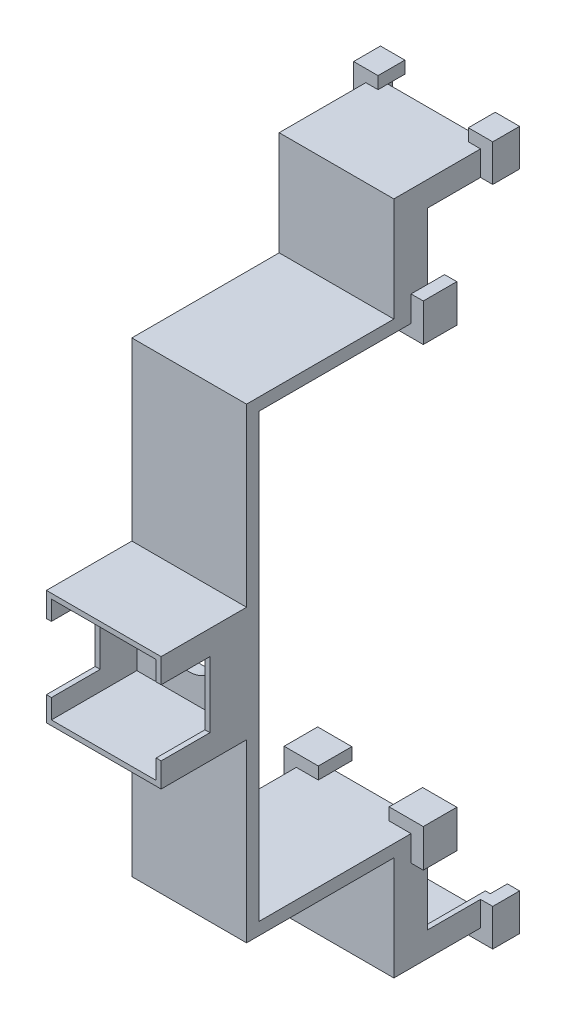
from build123d import *

# Parameters (mm, degrees)
SKETCH_1_W                = 46.3
SKETCH_1_H                = 47
EXTRUDE_1_DEPTH           = 50
SKETCH_2_W                = 46.3
SKETCH_2_H                = 42
CUT_EXTRUDE_1_DEPTH       = 32.3
SKETCH_3_W                = 42.3
SKETCH_3_H                = 40
CUT_EXTRUDE_2_DEPTH       = 10
SKETCH_4_W                = 42.3
SKETCH_4_H                = 37
CUT_EXTRUDE_3_DEPTH       = 8.7
SKETCH_5_W                = 2
SKETCH_5_H                = 22
SKETCH_5_W_2              = 26.3
SKETCH_5_H_2              = 2
CUT_EXTRUDE_4_DEPTH       = 5
SKETCH_7_W                = 10
SKETCH_7_H                = 5
EXTRUDE_2_DEPTH           = 2
SKETCH_8_W                = 10
SKETCH_8_H                = 5
EXTRUDE_3_DEPTH           = 2
SKETCH_9_W                = 22
SKETCH_9_H                = 21.15
CUT_EXTRUDE_5_DEPTH       = 6
SKETCH_11_R               = 2
EXTRUDE_4_DEPTH           = 4
SKETCH_12_R               = 2
CUT_EXTRUDE_6_DEPTH       = 4
SCALE_1_SCALE             = 1.015
SKETCH_13_W               = 33.453324454
SKETCH_13_H               = 20.869572599
CUT_EXTRUDE_7_DEPTH       = 57.79725
CUT_EXTRUDE_7_DEPTH_BACK  = 11.49725
EXTRUDE_START             = -47.22285
SKETCH_15_W               = 23.49725
SKETCH_15_H               = 95.575
EXTRUDE_5_DEPTH           = 5.075
SKETCH_16_R               = 11.165
CUT_EXTRUDE_9_DEPTH       = 1
CUT_EXTRUDE_9_DEPTH_BACK  = 48.222850293
SKETCH_17_W               = 23.49725
SKETCH_17_H               = 95.575
EXTRUDE_6_DEPTH           = 5.075
SKETCH_18_R               = 11.17
CUT_EXTRUDE_11_DEPTH      = 1
CUT_EXTRUDE_11_DEPTH_BACK = 48.222850293
EXTRUDE_START_2           = -42.14785
SKETCH_20_W               = 46.64725
SKETCH_20_H               = 4.191450632
EXTRUDE_7_DEPTH           = 10
EXTRUDE_START_3           = -66.517763
SKETCH_22_W               = 46.9945
SKETCH_22_H               = 69.05
EXTRUDE_8_DEPTH           = 5.075
SKETCH_24_W               = 13.7769009
SKETCH_24_H               = 42.63
EXTRUDE_10_DEPTH          = 46.9945
SKETCH_26_W               = 25.73
SKETCH_26_H               = 10.15
EXTRUDE_11_DEPTH          = 46.9945
CUT_EXTRUDE_START         = -142.00285
SKETCH_28_W               = 42.58725
SKETCH_28_H               = 7.64
CUT_EXTRUDE_13_DEPTH      = 25.73
EXTRUDE_12_DEPTH          = 7
EXTRUDE_12_2_DEPTH        = 7
EXTRUDE_14_DEPTH          = 7
EXTRUDE_14_2_DEPTH        = 7
EXTRUDE_15_DEPTH          = 4
EXTRUDE_16_DEPTH          = 6.73
SKETCH_31_W               = 24.506685575
SKETCH_31_H               = 120.544137908
CUT_EXTRUDE_14_DEPTH      = 11.15
CUT_EXTRUDE_14_DEPTH_BACK = 58.1445
SKETCH_34_W               = 46.9945
SKETCH_34_H               = 46.9945
EXTRUDE_17_DEPTH          = 35
SKETCH_33_W               = 42.9
SKETCH_33_H               = 42.9
CUT_EXTRUDE_15_DEPTH      = 35
SKETCH_35_W               = 20
SKETCH_35_H               = 26.9945
CUT_EXTRUDE_16_DEPTH      = 6
CUT_EXTRUDE_16_DEPTH_BACK = 52.9945


with BuildPart() as part:
    # 草圖1 → 填料-伸長1 (new body)
    with BuildSketch(Plane(origin=(0, 0, 0), x_dir=(1, 0, 0), z_dir=(0, 1, 0))):
        with Locations((23.15, 23.5)):
            Rectangle(SKETCH_1_W, SKETCH_1_H)
    extrude(amount=EXTRUDE_1_DEPTH)

    # 草圖2 → 除料-伸長1 (cut)
    with BuildSketch(Plane(origin=(0, 50, 0), x_dir=(1, 0, 0), z_dir=(0, 1, 0))):
        with Locations((23.15, 21)):
            Rectangle(SKETCH_2_W, SKETCH_2_H)
    extrude(amount=-CUT_EXTRUDE_1_DEPTH, mode=Mode.SUBTRACT)

    # 草圖3 → 除料-伸長2 (cut)
    with BuildSketch(Plane(origin=(0, 17.7, 0), x_dir=(1, 0, 0), z_dir=(0, 1, 0))):
        with Locations((23.15, 22)):
            Rectangle(SKETCH_3_W, SKETCH_3_H)
    extrude(amount=-CUT_EXTRUDE_2_DEPTH, mode=Mode.SUBTRACT)

    # 草圖4 → 除料-伸長3 (cut, through all)
    with BuildSketch(Plane(origin=(0, 7.7, 0), x_dir=(1, 0, 0), z_dir=(0, 1, 0))):
        with Locations((23.15, 23.5)):
            Rectangle(SKETCH_4_W, SKETCH_4_H)
    extrude(amount=-CUT_EXTRUDE_3_DEPTH, mode=Mode.SUBTRACT)

    # 草圖5 → 除料-伸長4 (cut)
    with BuildSketch(Plane(origin=(0, 17.7, 0), x_dir=(1, 0, 0), z_dir=(0, 1, 0))):
        with Locations((1, 21)):
            Rectangle(SKETCH_5_W, SKETCH_5_H)
        with Locations((45.3, 21)):
            Rectangle(SKETCH_5_W, SKETCH_5_H)
        with Locations((23.15, 1)):
            Rectangle(SKETCH_5_W_2, SKETCH_5_H_2)
    extrude(amount=-CUT_EXTRUDE_4_DEPTH, mode=Mode.SUBTRACT)

    # 草圖7 → 填料-伸長2 (add)
    with BuildSketch(Plane.ZY):
        with BuildLine():
            Line((-42, 32.7), (-42, 22.7))
            Line((-42, 22.7), (-32, 22.7))
            ThreePointArc((-32, 22.7), (-34.928932188, 29.771067812), (-42, 32.7))
        make_face()
        with Locations((-37, 20.2)):
            Rectangle(SKETCH_7_W, SKETCH_7_H)
    extrude(amount=-EXTRUDE_2_DEPTH)

    # 草圖8 → 填料-伸長3 (add)
    with BuildSketch(Plane(origin=(46.3, 0, 0), x_dir=(0, 0, -1), z_dir=(1, 0, 0))):
        with Locations((37, 20.2)):
            Rectangle(SKETCH_8_W, SKETCH_8_H)
        with BuildLine():
            Line((32, 22.7), (42, 22.7))
            Line((42, 22.7), (42, 32.7))
            ThreePointArc((42, 32.7), (34.928932188, 29.771067812), (32, 22.7))
        make_face()
    extrude(amount=-EXTRUDE_3_DEPTH)

    # 草圖9 → 除料-伸長5 (cut, through all)
    with BuildSketch(Plane.XY.offset(-42)):
        with BuildLine():
            ThreePointArc((34.15, 28.85), (23.15, 17.85), (12.15, 28.85))
            Line((12.15, 28.85), (34.15, 28.85))
        make_face()
        with Locations((23.15, 39.425)):
            Rectangle(SKETCH_9_W, SKETCH_9_H)
    extrude(amount=-CUT_EXTRUDE_5_DEPTH, mode=Mode.SUBTRACT)

    # 草圖11 → 填料-伸長4 (add)
    with BuildSketch(Plane.XZ):
        with BuildLine():
            Line((51.3, -5), (46.3, -5))
            Line((46.3, -5), (46.3, -15))
            Line((46.3, -15), (51.3, -15))
            ThreePointArc((51.3, -15), (56.3, -10), (51.3, -5))
        make_face()
        with Locations((51.3, -10)):
            Circle(SKETCH_11_R, mode=Mode.SUBTRACT)
        with BuildLine():
            Line((46.3, -32), (46.3, -42))
            Line((46.3, -42), (51.3, -42))
            ThreePointArc((51.3, -42), (56.3, -37), (51.3, -32))
            Line((51.3, -32), (46.3, -32))
        make_face()
        with Locations((51.3, -37)):
            Circle(SKETCH_11_R, mode=Mode.SUBTRACT)
        with BuildLine():
            Line((0, -15), (0, -5))
            Line((0, -5), (-5, -5))
            ThreePointArc((-5, -5), (-10, -10), (-5, -15))
            Line((-5, -15), (0, -15))
        make_face()
        with BuildLine():
            Line((0, -42), (0, -32))
            Line((0, -32), (-5, -32))
            ThreePointArc((-5, -32), (-10, -37), (-5, -42))
            Line((-5, -42), (0, -42))
        make_face()
        with Locations((-5, -37)):
            Circle(SKETCH_11_R, mode=Mode.SUBTRACT)
    extrude(amount=-EXTRUDE_4_DEPTH)

    # 草圖12 → 除料-伸長6 (cut)
    with BuildSketch(Plane.XZ):
        with Locations((-5, -10)):
            Circle(SKETCH_12_R)
    extrude(amount=-CUT_EXTRUDE_6_DEPTH, mode=Mode.SUBTRACT)


with BuildPart() as part_1:
    # 縮放比例1: scaled about (23.15, 15.034187995, -32.143313771)
    add(part.part.scale(SCALE_1_SCALE).moved(Location((-0.34725, -0.22551282, 0.482149707))))

    # 草圖13 → 除料-伸長7 (cut, two sides)
    with BuildSketch(Plane(origin=(0, 0, 0), x_dir=(0, 0, -1), z_dir=(1, 0, 0))) as cut_extrude_7_sk:
        with Locations((15.271188066, 10.20927348)):
            Rectangle(SKETCH_13_W, SKETCH_13_H)
    extrude(amount=CUT_EXTRUDE_7_DEPTH, mode=Mode.SUBTRACT)
    extrude(cut_extrude_7_sk.sketch, amount=-CUT_EXTRUDE_7_DEPTH_BACK, mode=Mode.SUBTRACT)

    # 草圖15 → 填料-伸長5 (add)
    with BuildSketch(Plane.XY.offset(EXTRUDE_START)):
        with Locations((34.898625, 76.84473718)):
            Rectangle(SKETCH_15_W, SKETCH_15_H)
    extrude_5 = extrude(amount=EXTRUDE_5_DEPTH)

    # 鏡射1: 填料-伸長5 across plane
    add(extrude_5.mirror(Plane(origin=(23.15, 50.52448718, 56.273191067), x_dir=(0, 0, 1), z_dir=(1, 0, 0))))

    # 草圖16 → 除料-伸長9 (cut, two sides)
    with BuildSketch(Plane.XY) as cut_extrude_9_sk:
        with Locations((23.15, 29.05723718)):
            Circle(SKETCH_16_R)
    extrude(amount=CUT_EXTRUDE_9_DEPTH, mode=Mode.SUBTRACT)
    extrude(cut_extrude_9_sk.sketch, amount=-CUT_EXTRUDE_9_DEPTH_BACK, mode=Mode.SUBTRACT)

    # 草圖17 → 填料-伸長6 (add)
    with BuildSketch(Plane.XY.offset(EXTRUDE_START)):
        with Locations((11.401375, -18.73026282)):
            Rectangle(SKETCH_17_W, SKETCH_17_H)
    extrude_6 = extrude(amount=EXTRUDE_6_DEPTH)

    # 鏡射2: 填料-伸長6 across plane
    add(extrude_6.mirror(Plane(origin=(23.15, 50.52448718, 56.273191067), x_dir=(0, 0, 1), z_dir=(-1, 0, 0))))

    # 草圖18 → 除料-伸長11 (cut, two sides)
    with BuildSketch(Plane.XY) as cut_extrude_11_sk:
        with Locations((23.15, 29.05723718)):
            Circle(SKETCH_18_R)
    extrude(amount=CUT_EXTRUDE_11_DEPTH, mode=Mode.SUBTRACT)
    extrude(cut_extrude_11_sk.sketch, amount=-CUT_EXTRUDE_11_DEPTH_BACK, mode=Mode.SUBTRACT)

    # 草圖20 → 填料-伸長7 (add)
    with BuildSketch(Plane.XY.offset(EXTRUDE_START_2)):
        with Locations((23.323625, -2.095725316)):
            Rectangle(SKETCH_20_W, SKETCH_20_H)
    extrude(amount=EXTRUDE_7_DEPTH)

    # 草圖22 → 填料-伸長8 (add)
    with BuildSketch(Plane(origin=(0, 0, 0), x_dir=(1, 0, 0), z_dir=(0, 1, 0)).offset(EXTRUDE_START_3)):
        with Locations((23.15, 81.747850293)):
            Rectangle(SKETCH_22_W, SKETCH_22_H)
    extrude(amount=EXTRUDE_8_DEPTH)

    # 草圖24 → 填料-伸長10 (add)
    with BuildSketch(Plane(origin=(-0.34725, 0, 0), x_dir=(0, 0, -1), z_dir=(1, 0, 0))):
        with Locations((109.384399843, -87.83276282)):
            Rectangle(SKETCH_24_W, SKETCH_24_H)
    extrude(amount=EXTRUDE_10_DEPTH)

    # 草圖26 → 填料-伸長11 (add)
    with BuildSketch(Plane(origin=(-0.34725, 0, 0), x_dir=(0, 0, -1), z_dir=(1, 0, 0))):
        with Locations((129.137850293, -104.07276282)):
            Rectangle(SKETCH_26_W, SKETCH_26_H)
    extrude(amount=EXTRUDE_11_DEPTH)

    # 草圖28 → 除料-伸長13 (cut)
    with BuildSketch(Plane.XY.offset(CUT_EXTRUDE_START)):
        with Locations((23.323625, -102.81776282)):
            Rectangle(SKETCH_28_W, SKETCH_28_H)
    extrude(amount=CUT_EXTRUDE_13_DEPTH, mode=Mode.SUBTRACT)



with BuildPart() as body_2:
    # 草圖29 → 填料-伸長12 (new body)
    with BuildSketch(Plane(origin=(0, 0, -116.272850293), x_dir=(-1, 0, 0), z_dir=(0, 0, -1))):
        Polygon((-37.64725, -61.44276282), (-37.64725, -56.44276282), (-51.64725, -56.44276282), (-51.64725, -71.914320692), (-46.64725, -71.914320692), (-46.64725, -61.44276282), align=None)
    extrude(amount=EXTRUDE_12_DEPTH)


with BuildPart() as body_3:
    # 草圖29 → Extrude 12 2 (new body)
    with BuildSketch(Plane(origin=(0, 0, -116.272850293), x_dir=(-1, 0, 0), z_dir=(0, 0, -1))):
        Polygon((-8.65275, -61.44276282), (-8.65275, -56.44276282), (5.34725, -56.44276282), (5.34725, -71.914320692), (0.34725, -71.914320692), (0.34725, -61.44276282), align=None)
    extrude(amount=EXTRUDE_12_2_DEPTH)


with BuildPart() as body_4:
    # 草圖30 → 填料-伸長14 (new body)
    with BuildSketch(Plane(origin=(0, 0, -142.002850293), x_dir=(-1, 0, 0), z_dir=(0, 0, -1))):
        Polygon((-41.64725, -109.14776282), (-41.64725, -114.14776282), (-51.64725, -114.14776282), (-51.64725, -98.99776282), (-46.64725, -98.99776282), (-46.64725, -109.14776282), align=None)
    extrude(amount=EXTRUDE_14_DEPTH)


with BuildPart() as body_5:
    # 草圖30 → Extrude 14 2 (new body)
    with BuildSketch(Plane(origin=(0, 0, -142.002850293), x_dir=(-1, 0, 0), z_dir=(0, 0, -1))):
        Polygon((-4.65275, -109.14776282), (0.34725, -109.14776282), (0.34725, -98.99776282), (5.34725, -98.99776282), (5.34725, -114.14776282), (-4.65275, -114.14776282), align=None)
    extrude(amount=EXTRUDE_14_2_DEPTH)


with BuildPart() as part_2:
    add(part_1.part)

    add(body_4.part)  # 填料-伸長15 merges body 4

    add(body_5.part)  # 填料-伸長15 merges body 5
    # 草圖30<2> → 填料-伸長15 (add)
    with BuildSketch(Plane(origin=(0, 0, -142.002850293), x_dir=(-1, 0, 0), z_dir=(0, 0, -1))):
        Polygon((-41.64725, -109.14776282), (-41.64725, -114.14776282), (-51.64725, -114.14776282), (-51.64725, -98.99776282), (-46.64725, -98.99776282), (-46.64725, -109.14776282), align=None)
        Polygon((-4.65275, -109.14776282), (0.34725, -109.14776282), (0.34725, -98.99776282), (5.34725, -98.99776282), (5.34725, -114.14776282), (-4.65275, -114.14776282), align=None)
    extrude(amount=-EXTRUDE_15_DEPTH)


    add(body_2.part)  # 填料-伸長16 merges body 2

    add(body_3.part)  # 填料-伸長16 merges body 3
    # 草圖29<5> → 填料-伸長16 (add)
    with BuildSketch(Plane(origin=(0, 0, -116.272850293), x_dir=(-1, 0, 0), z_dir=(0, 0, -1))):
        Polygon((-37.64725, -61.44276282), (-37.64725, -56.44276282), (-51.64725, -56.44276282), (-51.64725, -71.914320692), (-46.64725, -71.914320692), (-46.64725, -61.44276282), align=None)
        Polygon((-8.65275, -61.44276282), (-8.65275, -56.44276282), (5.34725, -56.44276282), (5.34725, -71.914320692), (0.34725, -71.914320692), (0.34725, -61.44276282), align=None)
    extrude(amount=-EXTRUDE_16_DEPTH)

    # 鏡射40: part across plane


with BuildPart() as part_3:
    add(part_2.part)
    add(part_2.part.mirror(Plane.ZX.offset(29.05723718)))

    # 草圖31 → 除料-伸長14 (cut, two sides)
    with BuildSketch(Plane.ZY.offset(0.34725)) as cut_extrude_14_sk:
        with Locations((-29.894507506, 20.212320412)):
            Rectangle(SKETCH_31_W, SKETCH_31_H)
    extrude(amount=CUT_EXTRUDE_14_DEPTH, mode=Mode.SUBTRACT)
    extrude(cut_extrude_14_sk.sketch, amount=-CUT_EXTRUDE_14_DEPTH_BACK, mode=Mode.SUBTRACT)

    # 草圖34 → 填料-伸長17 (add)
    with BuildSketch(Plane.XY.offset(-42.147850293)):
        with Locations((23.15, 29.05723718)):
            Rectangle(SKETCH_34_W, SKETCH_34_H)
    extrude(amount=EXTRUDE_17_DEPTH)

    # 草圖33 → 除料-伸長15 (cut)
    with BuildSketch(Plane.XY.offset(-42.147850293)):
        with Locations((23.15, 29.05723718)):
            Rectangle(SKETCH_33_W, SKETCH_33_H)
    extrude(amount=CUT_EXTRUDE_15_DEPTH, mode=Mode.SUBTRACT)

    # 草圖35 → 除料-伸長16 (cut, two sides)
    with BuildSketch(Plane.ZY.offset(0.34725)) as cut_extrude_16_sk:
        with Locations((-17.147850293, 29.05723718)):
            Rectangle(SKETCH_35_W, SKETCH_35_H)
    extrude(amount=CUT_EXTRUDE_16_DEPTH, mode=Mode.SUBTRACT)
    extrude(cut_extrude_16_sk.sketch, amount=-CUT_EXTRUDE_16_DEPTH_BACK, mode=Mode.SUBTRACT)


solid = part_3.part
